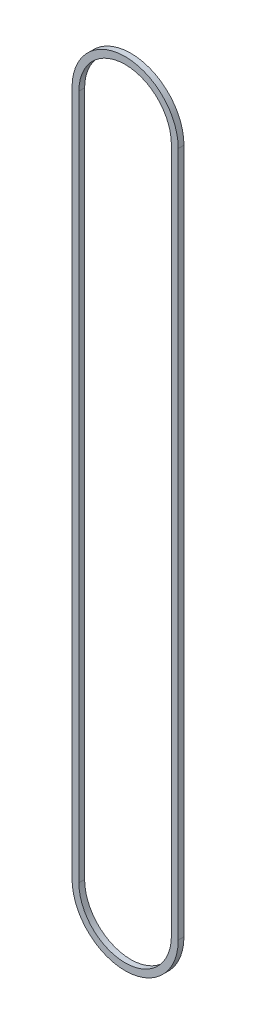
from build123d import *

# Parameters (mm, degrees)
BOSS_EXTRUDE1_DEPTH = 6.35


with BuildPart() as part:
    # Sketch1 → Boss-Extrude1 (new body)
    with BuildSketch(Plane.XY):
        with BuildLine():
            Line((-59.0169, 0), (-59.0169, 762))
            ThreePointArc((-59.0169, 762), (0, 821.0169), (59.0169, 762))
            Line((59.0169, 762), (59.0169, 0))
            ThreePointArc((59.0169, 0), (0, -59.0169), (-59.0169, 0))
        make_face()
        with BuildLine():
            Line((-51.3969, 0), (-51.3969, 762))
            ThreePointArc((-51.3969, 762), (0, 813.3969), (51.3969, 762))
            Line((51.3969, 762), (51.3969, 0))
            ThreePointArc((51.3969, 0), (0, -51.3969), (-51.3969, 0))
        make_face(mode=Mode.SUBTRACT)
    extrude(amount=BOSS_EXTRUDE1_DEPTH)


solid = part.part
